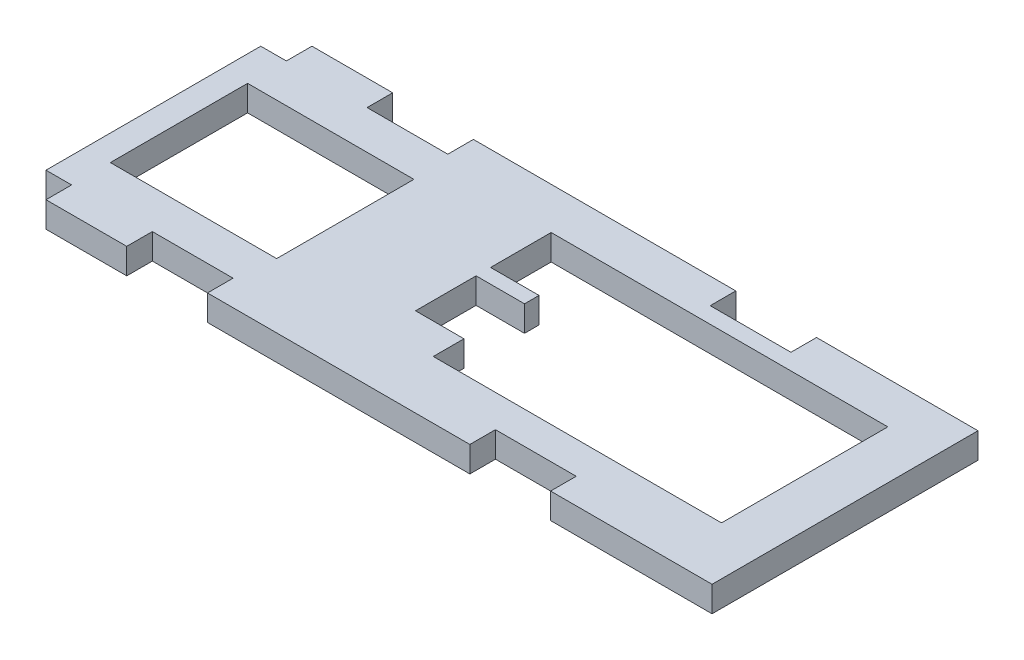
from build123d import *

# Parameters (mm, degrees)
SKETCH1_W           = 20.6
SKETCH1_H           = 17
BOSS_EXTRUDE1_DEPTH = 3.17


with BuildPart() as part:
    # Sketch1 → Boss-Extrude1 (new body)
    with BuildSketch(Plane(origin=(0, 0, 0), x_dir=(1, 0, 0), z_dir=(0, 1, 0))):
        Polygon((55.67, 29.77), (55.67, 32.94), (23.17, 32.94), (23.17, 29.77), (13.17, 29.77), (13.17, 32.94), (3.17, 32.94), (3.17, 29.77), (0, 29.77), (0, 3.17), (3.17, 3.17), (3.17, 0), (13.17, 0), (13.17, 3.17), (23.17, 3.17), (23.17, 0), (55.67, 0), (55.67, 3.17), (65.67, 3.17), (65.67, 0), (85.67, 0), (85.67, 32.94), (65.67, 32.94), (65.67, 29.77), align=None)
        with Locations((13.47, 16.47)):
            Rectangle(SKETCH1_W, SKETCH1_H, mode=Mode.SUBTRACT)
        Polygon((37.97, 27.77), (43.97, 27.77), (79.67, 27.77), (79.67, 7.17), (43.97, 7.17), (43.97, 10.97), (37.97, 10.97), (37.97, 18.47), (43.97, 18.47), (43.97, 20.27), (37.97, 20.27), align=None, mode=Mode.SUBTRACT)
    extrude(amount=-BOSS_EXTRUDE1_DEPTH)


solid = part.part
